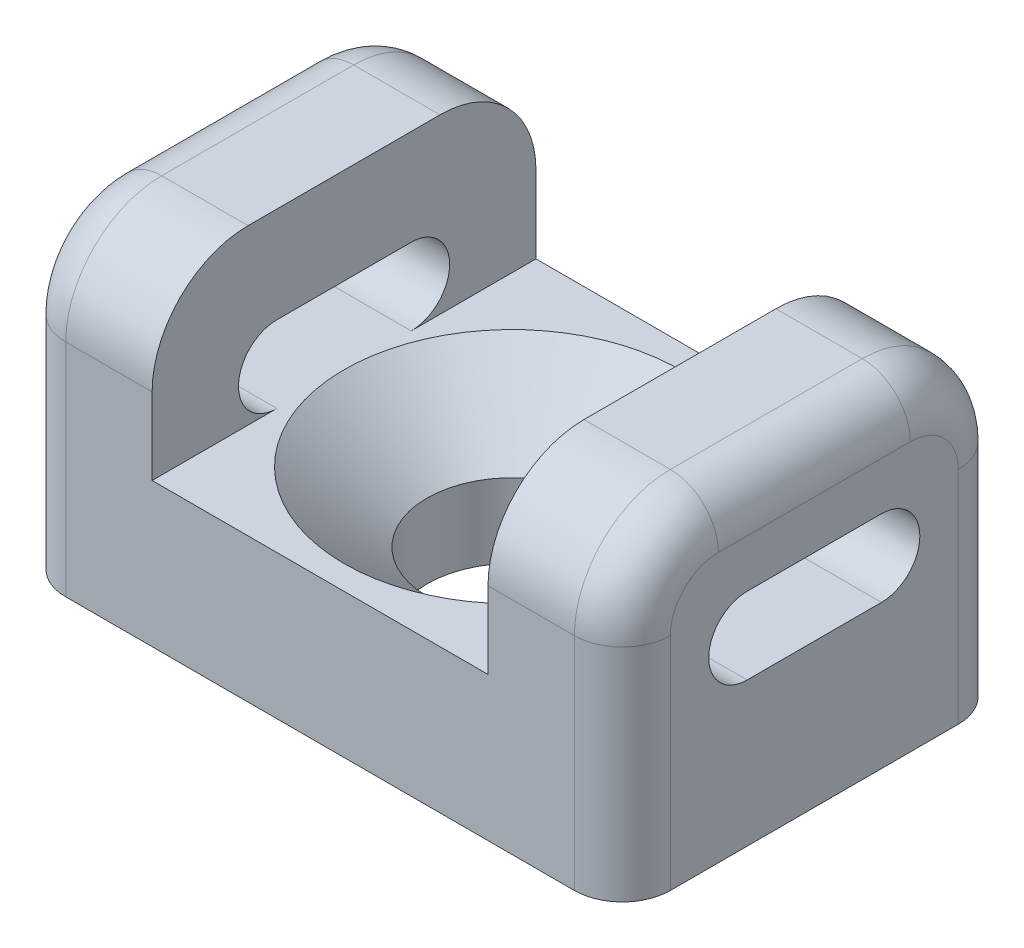
from build123d import *

# Parameters (mm, degrees)
BOSS_EXTRUDE2_DEPTH                               = 5.08
CSK_FOR_8_FLAT_HEAD_MACHINE_SCREW_100_D           = 4.4958
CSK_FOR_8_FLAT_HEAD_MACHINE_SCREW_100_CSINK_D     = 8.89
CSK_FOR_8_FLAT_HEAD_MACHINE_SCREW_100_CSINK_ANGLE = 100
CUT_EXTRUDE1_DEPTH                                = 4.556
FILLET1_R                                         = 2.54
FILLET2_R                                         = 1.27


with BuildPart() as part:
    # Sketch4 → Boss-Extrude2 (new body, symmetric)
    with BuildSketch(Plane.XY):
        Polygon((0, 0), (4.445, 0), (4.445, 4.572), (8.001, 4.572), (8.001, -3.81), (0, -3.81), align=None)
    extrude(amount=BOSS_EXTRUDE2_DEPTH, both=True)

    # CSK for #8 Flat Head Machine Screw (100)2 (through all)
    with Locations(Plane(origin=(0, 0, 0), x_dir=(1, 0, 0), z_dir=(0, 1, 0))):
        with Locations((0, 0)):
            CounterSinkHole(CSK_FOR_8_FLAT_HEAD_MACHINE_SCREW_100_D / 2, CSK_FOR_8_FLAT_HEAD_MACHINE_SCREW_100_CSINK_D / 2, counter_sink_angle=CSK_FOR_8_FLAT_HEAD_MACHINE_SCREW_100_CSINK_ANGLE)

    # Sketch7 → Cut-Extrude1 (cut, through all)
    with BuildSketch(Plane.ZY.offset(-4.445)):
        with BuildLine():
            Line((-1.778, 2.032), (1.778, 2.032))
            ThreePointArc((1.778, 2.032), (2.794, 1.016), (1.778, 0))
            Line((1.778, 0), (-1.778, 0))
            ThreePointArc((-1.778, 0), (-2.794, 1.016), (-1.778, 2.032))
        make_face()
    extrude(amount=-CUT_EXTRUDE1_DEPTH, mode=Mode.SUBTRACT)

    # Fillet1
    fillet1_edges = [part.edges().sort_by_distance(p)[0] for p in [
        (6.223, 4.572, 5.08),
        (6.223, 4.572, -5.08),
    ]]
    fillet(fillet1_edges, radius=FILLET1_R)

    # Fillet2
    fillet2_edges = [part.edges().sort_by_distance(p)[0] for p in [
        (8.001, -0.889, 5.08),
        (8.001, 4.572, 0),
        (8.001, 3.828051224, 4.336051224),
        (8.001, 3.828051224, -4.336051224),
        (8.001, -0.889, -5.08),
    ]]
    fillet(fillet2_edges, radius=FILLET2_R)

    # Mirror2: part across plane


with BuildPart() as part_1:
    add(part.part)
    add(part.part.mirror(Plane(origin=(0, 0, 0), x_dir=(0, 0, 1), z_dir=(1, 0, 0))))


solid = part_1.part
